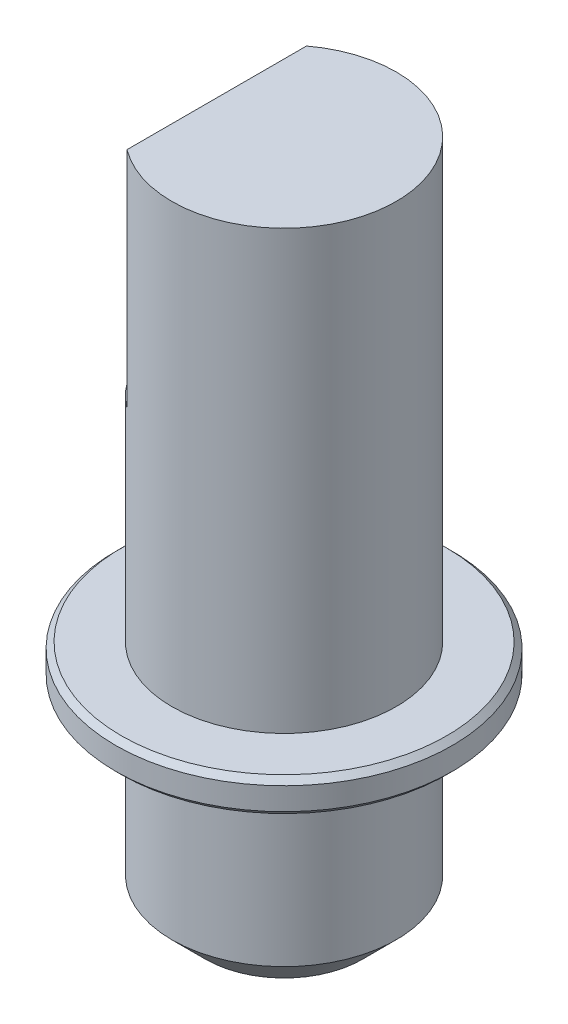
from build123d import *

# Parameters (mm, degrees)
SKETCH1_R           = 10
BOSS_EXTRUDE1_DEPTH = 60
SKETCH2_R           = 4
CUT_EXTRUDE1_DEPTH  = 15
BOSS_EXTRUDE2_REACH = 62
CUT_EXTRUDE2_DEPTH  = 20
CHAMFER3_SIZE       = 3
BOSS_EXTRUDE3_START = 18
SKETCH5_R           = 15
BOSS_EXTRUDE3_DEPTH = 3
CHAMFER4_SIZE       = 0.5


with BuildPart() as part:
    # Sketch1 → Boss-Extrude1 (new body)
    with BuildSketch(Plane(origin=(0, 0, 0), x_dir=(1, 0, 0), z_dir=(0, 1, 0))):
        Circle(SKETCH1_R)
    extrude(amount=BOSS_EXTRUDE1_DEPTH)

    # Sketch2 → Cut-Extrude1 (cut)
    with BuildSketch(Plane.XZ):
        Circle(SKETCH2_R)
    extrude(amount=-CUT_EXTRUDE1_DEPTH, mode=Mode.SUBTRACT)

    # Sketch3 → Boss-Extrude2 (add, up to next)
    with BuildSketch(Plane.XZ, mode=Mode.PRIVATE) as boss_extrude2_sk1:
        with BuildLine():
            Line((-2.5, 3.122498999), (-2.5, -3.122498999))
            ThreePointArc((-2.5, -3.122498999), (-4, 0), (-2.5, 3.122498999))
        make_face()
    boss_extrude2_tool1 = extrude(boss_extrude2_sk1.sketch, amount=-BOSS_EXTRUDE2_REACH, mode=Mode.PRIVATE) - part.part
    add(boss_extrude2_tool1.solids().sort_by_distance((-3.110827, 0, 0))[0])

    # Sketch4 → Cut-Extrude2 (cut)
    with BuildSketch(Plane(origin=(0, 60, 0), x_dir=(1, 0, 0), z_dir=(0, 1, 0))):
        with BuildLine():
            Line((-6, 8), (-6, -8))
            ThreePointArc((-6, -8), (-10, 0), (-6, 8))
        make_face()
    extrude(amount=-CUT_EXTRUDE2_DEPTH, mode=Mode.SUBTRACT)

    # Chamfer3
    chamfer3_edges = [part.edges().sort_by_distance(p)[0] for p in [
        (-10, 0, 0),
    ]]
    chamfer(chamfer3_edges, length=CHAMFER3_SIZE)

    # Sketch5 → Boss-Extrude3 (add)
    with BuildSketch(Plane(origin=(0, 0, 0), x_dir=(1, 0, 0), z_dir=(0, 1, 0)).offset(BOSS_EXTRUDE3_START)):
        Circle(SKETCH5_R)
    extrude(amount=BOSS_EXTRUDE3_DEPTH)

    # Chamfer4
    chamfer4_edges = [part.edges().sort_by_distance(p)[0] for p in [
        (-15, 18, 0),
        (-15, 21, 0),
    ]]
    chamfer(chamfer4_edges, length=CHAMFER4_SIZE)


solid = part.part
